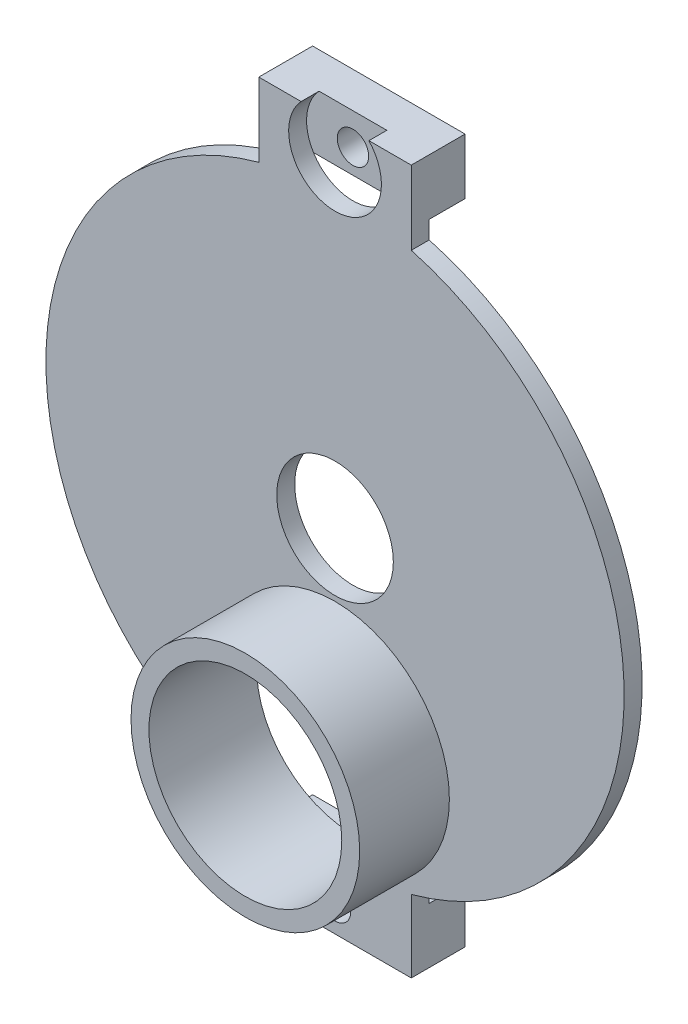
from build123d import *

# Parameters (mm, degrees)
SKETCH_1_W          = 17
SKETCH_1_H          = 6.237893195
SKETCH_1_R          = 1.75
EXTRUDE_1_DEPTH     = 4
SKETCH_1_H_2        = 6.200638702
EXTRUDE_1_2_DEPTH   = 4
SKETCH_3_R          = 10.75
SKETCH_3_R_2        = 1.75
EXTRUDE_3_DEPTH     = 2
SKETCH_4_R          = 6.5
CUT_EXTRUDE_1_DEPTH = 10
SKETCH_5_R          = 12.75
SKETCH_5_R_2        = 10.75
EXTRUDE_1_3_DEPTH   = 10
SKETCH_6_R          = 5.171558732
CUT_EXTRUDE_2_DEPTH = 2


with BuildPart() as part:
    # 草图1 → Extrude 1 (new body)
    with BuildSketch(Plane.XY):
        with Locations((0, -116.390757476)):
            Rectangle(SKETCH_1_W, SKETCH_1_H)
        with Locations((0, -116.802352716)):
            Circle(SKETCH_1_R, mode=Mode.SUBTRACT)
    extrude(amount=EXTRUDE_1_DEPTH)



with BuildPart() as body_2:
    # 草图1 → Extrude 1 2 (new body)
    with BuildSketch(Plane.XY):
        with Locations((0, -188.663897323)):
            Rectangle(SKETCH_1_W, SKETCH_1_H_2)
        with Locations((0, -188.764216674)):
            Circle(SKETCH_1_R, mode=Mode.SUBTRACT)
    extrude(amount=EXTRUDE_1_2_DEPTH)


with BuildPart() as part_1:
    add(part.part)

    add(body_2.part)  # 凸台-拉伸3 merges body 2
    # 草图3 → 凸台-拉伸3 (add)
    with BuildSketch(Plane.XY.offset(4)):
        with BuildLine():
            Line((-8.5, -113.271810879), (8.5, -113.271810879))
            Line((8.5, -113.271810879), (8.5, -121.50085412))
            ThreePointArc((8.5, -121.50085412), (32.236701024, -152.596752449), (8.5, -183.692650779))
            Line((8.5, -183.692650779), (8.5, -191.764216674))
            Line((8.5, -191.764216674), (-8.5, -191.764216674))
            Line((-8.5, -191.764216674), (-8.5, -183.692650779))
            ThreePointArc((-8.5, -183.692650779), (-32.236701024, -152.596752449), (-8.5, -121.50085412))
            Line((-8.5, -121.50085412), (-8.5, -113.271810879))
        make_face()
        with Locations((0, -172.399709936)):
            Circle(SKETCH_3_R, mode=Mode.SUBTRACT)
        with Locations((0, -188.764216674)):
            Circle(SKETCH_3_R_2, mode=Mode.SUBTRACT)
        with Locations((0, -116.802352716)):
            Circle(SKETCH_3_R_2, mode=Mode.SUBTRACT)
    extrude(amount=EXTRUDE_3_DEPTH)

    # 草图4 → 切除-拉伸1 (cut)
    with BuildSketch(Plane.XY.offset(6)):
        with Locations((0, -152.596752449)):
            Circle(SKETCH_4_R)
    extrude(amount=-CUT_EXTRUDE_1_DEPTH, mode=Mode.SUBTRACT)

    # 草图5 → Extrude 1 3 (add)
    with BuildSketch(Plane.XY.offset(6)):
        with Locations((0, -172.399709936)):
            Circle(SKETCH_5_R)
        with Locations((0, -172.399709936)):
            Circle(SKETCH_5_R_2, mode=Mode.SUBTRACT)
    extrude(amount=EXTRUDE_1_3_DEPTH)

    # 草图6 → 切除-拉伸2 (cut)
    with BuildSketch(Plane.XY.offset(6)):
        with Locations((0, -116.802352716)):
            Circle(SKETCH_6_R)
    extrude(amount=-CUT_EXTRUDE_2_DEPTH, mode=Mode.SUBTRACT)


solid = part_1.part
